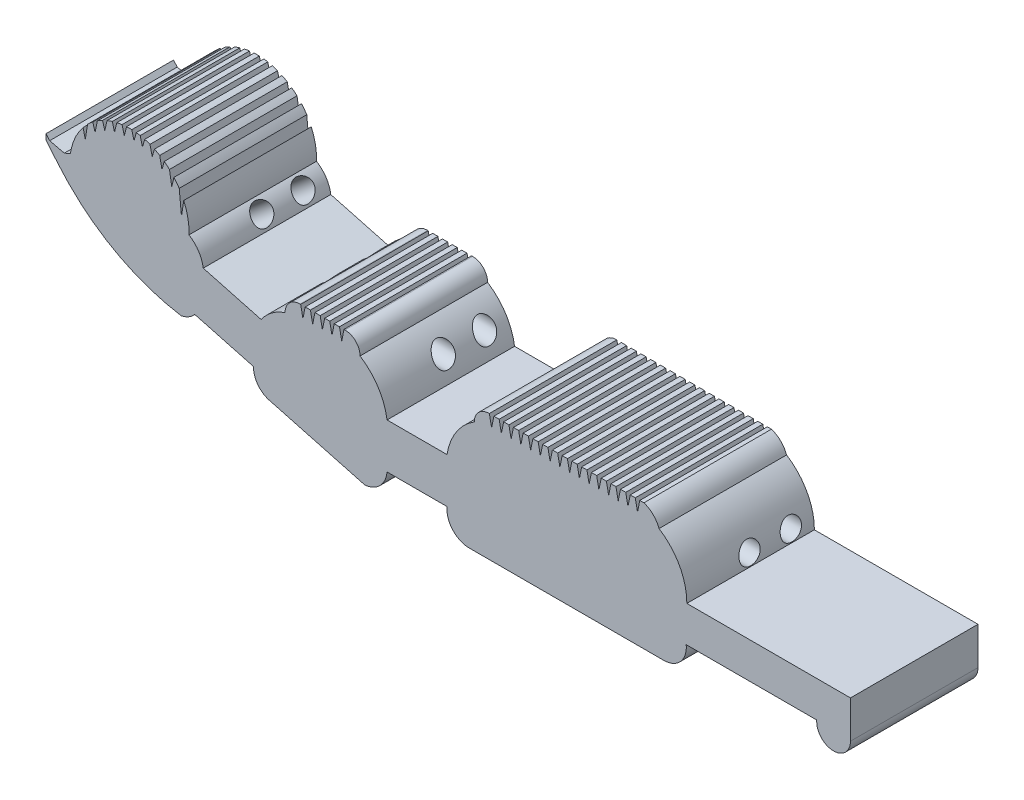
from build123d import *

# Parameters (mm, degrees)
BOSS_EXTRUDE1_DEPTH     = 17
CUT_EXTRUDE1_DEPTH      = 20
CUT_EXTRUDE1_DEPTH_BACK = 5
SKETCH2_R               = 1.4
SKETCH3_R               = 1.4
CUT_EXTRUDE2_DEPTH      = 42
SKETCH4_R               = 1.4
CUT_EXTRUDE3_DEPTH      = 4
CUT_EXTRUDE4_DEPTH      = 12
CUT_EXTRUDE4_DEPTH_BACK = 12
SKETCH5_R               = 1.4


with BuildPart() as part:
    # Sketch1 → Boss-Extrude1 (new body)
    with BuildSketch(Plane.XY):
        with BuildLine():
            Line((-37.939604241, 12.057000798), (-38.242861571, 13.562681784))
            ThreePointArc((-38.242861571, 13.562681784), (-39.080840003, 13.388801387), (-39.768674309, 12.879560568))
            ThreePointArc((-39.768674309, 12.879560568), (-40.127958641, 12.277263859), (-40.253022932, 11.587187429))
            ThreePointArc((-40.253022932, 11.587187429), (-42.676178233, 9.189861051), (-43.877694712, 6))
            Line((-43.877694712, 6), (-51.877694712, 6))
            ThreePointArc((-51.877694712, 6), (-53.067464891, 9.186046203), (-55.475984002, 11.587187427))
            ThreePointArc((-55.475984002, 11.587187427), (-56.061770439, 13.001400989), (-57.475984002, 13.587187427))
            Line((-57.475984002, 13.587187427), (-57.618140332, 13.587152417))
            Line((-57.618140332, 13.587152417), (-57.918140332, 12.087152417))
            Line((-57.918140332, 12.087152417), (-58.218140332, 13.587152417))
            Line((-58.218140332, 13.587152417), (-58.918140332, 13.587152417))
            Line((-58.918140332, 13.587152417), (-59.218140332, 12.087152417))
            Line((-59.218140332, 12.087152417), (-59.518140332, 13.587152417))
            Line((-59.518140332, 13.587152417), (-60.192130322, 13.587152417))
            Line((-60.192130322, 13.587152417), (-60.492130322, 12.087152417))
            Line((-60.492130322, 12.087152417), (-60.792130322, 13.587152417))
            Line((-60.792130322, 13.587152417), (-61.492130322, 13.587152417))
            Line((-61.492130322, 13.587152417), (-61.792130322, 12.087152417))
            Line((-61.792130322, 12.087152417), (-62.092130322, 13.587152417))
            Line((-62.092130322, 13.587152417), (-62.792130322, 13.587152417))
            Line((-62.792130322, 13.587152417), (-63.092130322, 12.087152417))
            Line((-63.092130322, 12.087152417), (-63.392130322, 13.587152417))
            Line((-63.392130322, 13.587152417), (-63.475984002, 13.587187427))
            ThreePointArc((-63.475984002, 13.587187427), (-64.890197564, 13.001400989), (-65.475984002, 11.587187427))
            ThreePointArc((-65.475984002, 11.587187427), (-67.261796695, 10.657633974), (-68.65060524, 9.200099267))
            Line((-68.65060524, 9.200099267), (-76.37720701, 11.273653002))
            ThreePointArc((-76.37720701, 11.273653002), (-77.003972517, 12.931276746), (-78.279703196, 14.161342889))
            ThreePointArc((-78.279703196, 14.161342889), (-78.41850315, 16.015917041), (-78.979703196, 17.788983657))
            Line((-78.979703196, 17.788983657), (-79.279703196, 15.788983657))
            Line((-79.279703196, 15.788983657), (-79.579703196, 18.886445887))
            ThreePointArc((-79.579703196, 18.886445887), (-79.913131782, 19.359295905), (-80.279703196, 19.80694215))
            Line((-80.279703196, 19.80694215), (-80.579703196, 18.60694215))
            Line((-80.579703196, 18.60694215), (-80.879703196, 20.418978121))
            ThreePointArc((-80.879703196, 20.418978121), (-81.221643376, 20.715190027), (-81.579703196, 20.991699964))
            Line((-81.579703196, 20.991699964), (-81.879703196, 19.891699964))
            Line((-81.879703196, 19.891699964), (-82.179703196, 21.388832339))
            ThreePointArc((-82.179703196, 21.388832339), (-82.525087526, 21.58440833), (-82.879703196, 21.762700312))
            Line((-82.879703196, 21.762700312), (-83.179703196, 20.762700312))
            Line((-83.179703196, 20.762700312), (-83.479703196, 22.016832542))
            ThreePointArc((-83.479703196, 22.016832542), (-83.827097574, 22.138631394), (-84.179703196, 22.244400436))
            Line((-84.179703196, 22.244400436), (-84.479703196, 21.194400436))
            Line((-84.479703196, 21.194400436), (-84.779703196, 22.385009274))
            ThreePointArc((-84.779703196, 22.385009274), (-85.040043423, 22.429657287), (-85.302096458, 22.462803722))
            Line((-85.302096458, 22.462803722), (-85.602096458, 21.362803722))
            Line((-85.602096458, 21.362803722), (-85.902096458, 22.502702907))
            ThreePointArc((-85.902096458, 22.502702907), (-86.252834881, 22.505221723), (-86.603349399, 22.492440559))
            Line((-86.603349399, 22.492440559), (-86.903349399, 21.30183172))
            Line((-86.903349399, 21.30183172), (-87.203349399, 22.43481024))
            ThreePointArc((-87.203349399, 22.43481024), (-87.553628489, 22.379969596), (-87.901149208, 22.309739348))
            Line((-87.901149208, 22.309739348), (-88.201149208, 21.052626673))
            Line((-88.201149208, 21.052626673), (-88.501149208, 22.150077213))
            ThreePointArc((-88.501149208, 22.150077213), (-88.853793202, 22.032502704), (-89.200625639, 21.898753635))
            Line((-89.200625639, 21.898753635), (-89.500625639, 20.598753635))
            Line((-89.500625639, 20.598753635), (-89.800625639, 21.621921495))
            ThreePointArc((-89.800625639, 21.621921495), (-90.15475534, 21.429164643), (-90.498776289, 21.218896631))
            Line((-90.498776289, 21.218896631), (-90.798776289, 19.718896631))
            Line((-90.798776289, 19.718896631), (-91.098776289, 20.790963939))
            ThreePointArc((-91.098776289, 20.790963939), (-91.45857676, 20.491264542), (-91.800318967, 20.171126493))
            Line((-91.800318967, 20.171126493), (-92.100318967, 18.271126493))
            Line((-92.100318967, 18.271126493), (-92.400318967, 19.504858553))
            ThreePointArc((-92.400318967, 19.504858553), (-93.50388964, 17.682147833), (-94.089904764, 15.633555909))
            ThreePointArc((-94.089904764, 15.633555909), (-94.496717663, 15.467187125), (-94.899287413, 15.290798622))
            Line((-94.899287413, 15.290798622), (-96.844564651, 15.755445227))
            Line((-96.844564651, 15.755445227), (-97.338516987, 16.319813095))
            Line((-97.338516987, 16.319813095), (-97.338516987, 15.569813095))
            Line((-97.338516987, 15.569813095), (-95.734886307, 13.651905734))
            ThreePointArc((-95.734886307, 13.651905734), (-88.376531163, 7.502211719), (-79.334632277, 4.307185672))
            ThreePointArc((-79.334632277, 4.307185672), (-78.330959024, 4.67325399), (-77.519207422, 5.367822451))
            Line((-77.519207422, 5.367822451), (-69.678572159, 3.263666056))
            ThreePointArc((-69.678572159, 3.263666056), (-69.055717522, 1.403484439), (-67.384538308, 0.376165802))
            Line((-67.384538308, 0.376165802), (-54.828810432, -2.993359017))
            ThreePointArc((-54.828810432, -2.993359017), (-52.811074833, -2.032549949), (-51.882015243, 0))
            Line((-51.882015243, 0), (-43.882015243, 0))
            ThreePointArc((-43.882015243, 0), (-43.111258036, -2.334659895), (-40.854012627, -3.309106743))
            Line((-40.854012627, -3.309106743), (-15.028002616, -3.309106743))
            ThreePointArc((-15.028002616, -3.309106743), (-12.770757207, -2.334659895), (-12, 0))
            Line((-12, 0), (0, 0))
            Line((0, 0), (5.39540601, 0))
            Line((5.39540601, 0), (5.39540601, -0.2))
            ThreePointArc((5.39540601, -0.2), (7.64540601, -2.45), (9.89540601, -0.2))
            Line((9.89540601, -0.2), (9.89540601, 4.8))
            Line((9.89540601, 4.8), (5.39540601, 4.8))
            Line((5.39540601, 4.8), (0, 4.8))
            Line((0, 4.8), (-11.916444412, 4.8))
            ThreePointArc((-11.916444412, 4.8), (-12.893220694, 8.672933089), (-15.624671639, 11.587187429))
            ThreePointArc((-15.624671639, 11.587187429), (-16.404743298, 12.801712029), (-17.634833, 13.557000799))
            Line((-17.634833, 13.557000799), (-18.188366933, 13.557000799))
            Line((-18.188366933, 13.557000799), (-18.488366933, 12.057000798))
            Line((-18.488366933, 12.057000798), (-18.788366933, 13.557000798))
            Line((-18.788366933, 13.557000798), (-19.462356923, 13.557000798))
            Line((-19.462356923, 13.557000798), (-19.762356923, 12.057000798))
            Line((-19.762356923, 12.057000798), (-20.062356923, 13.557000798))
            Line((-20.062356923, 13.557000798), (-20.762356923, 13.557000798))
            Line((-20.762356923, 13.557000798), (-21.062356923, 12.057000798))
            Line((-21.062356923, 12.057000798), (-21.362356923, 13.557000798))
            Line((-21.362356923, 13.557000798), (-22.036346912, 13.557000798))
            Line((-22.036346912, 13.557000798), (-22.336346912, 12.057000798))
            Line((-22.336346912, 12.057000798), (-22.636346912, 13.557000798))
            Line((-22.636346912, 13.557000798), (-23.336346912, 13.557000798))
            Line((-23.336346912, 13.557000798), (-23.636346912, 12.057000798))
            Line((-23.636346912, 12.057000798), (-23.936346912, 13.557000798))
            Line((-23.936346912, 13.557000798), (-24.636346912, 13.557000798))
            Line((-24.636346912, 13.557000798), (-24.936346912, 12.057000798))
            Line((-24.936346912, 12.057000798), (-25.236346912, 13.557000798))
            Line((-25.236346912, 13.557000798), (-25.936346912, 13.557000798))
            Line((-25.936346912, 13.557000798), (-26.236346912, 12.057000798))
            Line((-26.236346912, 12.057000798), (-26.536346912, 13.557000798))
            Line((-26.536346912, 13.557000798), (-27.236346912, 13.557000798))
            Line((-27.236346912, 13.557000798), (-27.536346912, 12.057000798))
            Line((-27.536346912, 12.057000798), (-27.836346912, 13.557000798))
            Line((-27.836346912, 13.557000798), (-28.536346912, 13.557000798))
            Line((-28.536346912, 13.557000798), (-28.836346912, 12.057000798))
            Line((-28.836346912, 12.057000798), (-29.136346912, 13.557000798))
            Line((-29.136346912, 13.557000798), (-29.836346912, 13.557000798))
            Line((-29.836346912, 13.557000798), (-30.136346912, 12.057000798))
            Line((-30.136346912, 12.057000798), (-30.436346912, 13.557000798))
            Line((-30.436346912, 13.557000798), (-31.136346912, 13.557000798))
            Line((-31.136346912, 13.557000798), (-31.436346912, 12.057000798))
            Line((-31.436346912, 12.057000798), (-31.736346912, 13.557000798))
            Line((-31.736346912, 13.557000798), (-32.436346912, 13.557000798))
            Line((-32.436346912, 13.557000798), (-32.736346912, 12.057000798))
            Line((-32.736346912, 12.057000798), (-33.036346912, 13.557000798))
            Line((-33.036346912, 13.557000798), (-33.736346912, 13.557000798))
            Line((-33.736346912, 13.557000798), (-34.036346912, 12.057000798))
            Line((-34.036346912, 12.057000798), (-34.336346912, 13.557000798))
            Line((-34.336346912, 13.557000798), (-35.036346912, 13.557000798))
            Line((-35.036346912, 13.557000798), (-35.336346912, 12.057000798))
            Line((-35.336346912, 12.057000798), (-35.636346912, 13.557000798))
            Line((-35.636346912, 13.557000798), (-36.336346912, 13.557000798))
            Line((-36.336346912, 13.557000798), (-36.636346912, 12.057000798))
            Line((-36.636346912, 12.057000798), (-36.936346912, 13.557000798))
            Line((-36.936346912, 13.557000798), (-37.636346912, 13.557000798))
            Line((-37.636346912, 13.557000798), (-37.939604241, 12.057000798))
        make_face()
    extrude(amount=BOSS_EXTRUDE1_DEPTH)

    # Sketch2 → Cut-Extrude1 (cut, two sides: drawn at the far end of the back side and taken through both)
    with BuildSketch(Plane(origin=(-60, 0, 0), x_dir=(0, 0, -1), z_dir=(1, 0, 0)).offset(-CUT_EXTRUDE1_DEPTH_BACK)):
        with Locations((-3, 8.793593713)):
            Circle(SKETCH2_R)
        with Locations((-8.5, 8.793593713)):
            Circle(SKETCH2_R)
    extrude(amount=CUT_EXTRUDE1_DEPTH + CUT_EXTRUDE1_DEPTH_BACK, mode=Mode.SUBTRACT)

    # Sketch3 → Cut-Extrude2 (cut)
    with BuildSketch(Plane(origin=(0, 0, 0), x_dir=(0, 0, -1), z_dir=(1, 0, 0))):
        with Locations((-3, 6.3)):
            Circle(SKETCH3_R)
        with Locations((-8.5, 6.3)):
            Circle(SKETCH3_R)
    extrude(amount=-CUT_EXTRUDE2_DEPTH, mode=Mode.SUBTRACT)

    # Sketch4 → Cut-Extrude3 (cut)
    with BuildSketch(Plane(origin=(-63.562453147, 23.162804969, 0), x_dir=(0, 0, -1), z_dir=(0.9395597001849917, -0.3423851191104667, 0))):
        with Locations((-3, -13.19602569)):
            Circle(SKETCH4_R)
        with Locations((-8.5, -13.19602569)):
            Circle(SKETCH4_R)
    extrude(amount=CUT_EXTRUDE3_DEPTH, mode=Mode.SUBTRACT)

    # Sketch5 → Cut-Extrude4 (cut, two sides: drawn at the far end of the back side and taken through both)
    with BuildSketch(Plane(origin=(-39.298770775, -32.949580164, 0), x_dir=(0, 0, -1), z_dir=(0.7662940611199174, 0.6424900091770644, 0)).offset(-CUT_EXTRUDE4_DEPTH_BACK)):
        with Locations((-3, 59.428102976)):
            Circle(SKETCH5_R)
        with Locations((-8.5, 59.428102976)):
            Circle(SKETCH5_R)
    extrude(amount=CUT_EXTRUDE4_DEPTH + CUT_EXTRUDE4_DEPTH_BACK, mode=Mode.SUBTRACT)


solid = part.part
